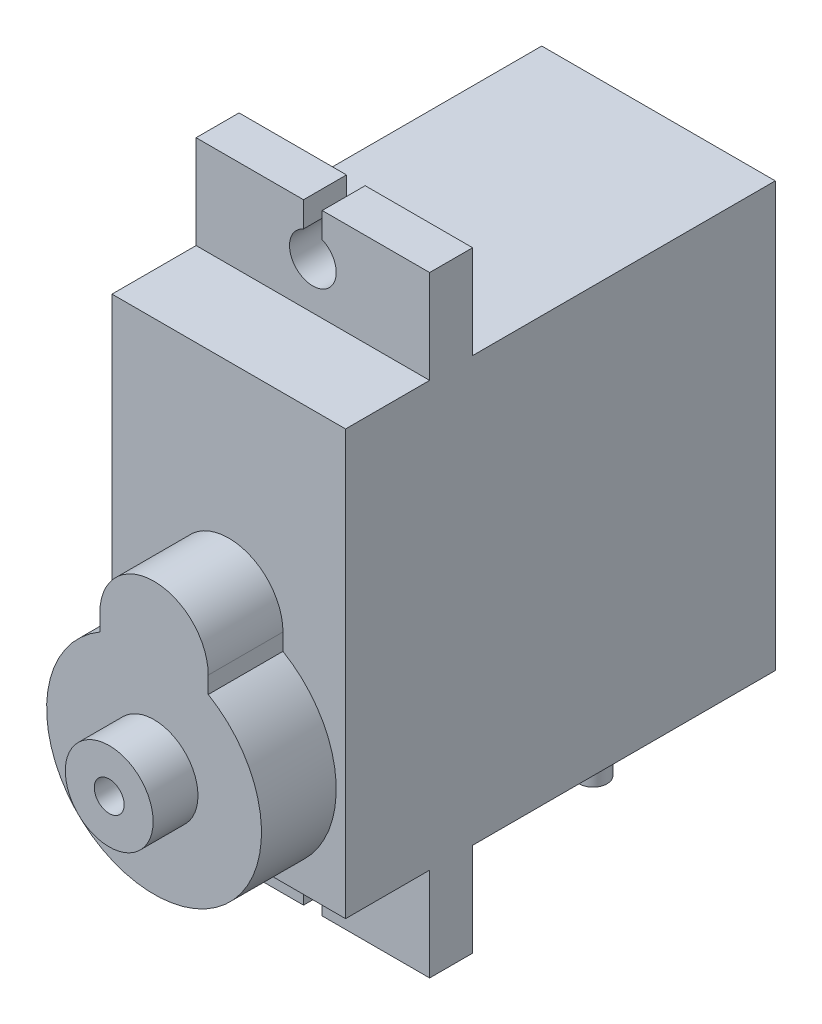
from build123d import *

# Parameters (mm, degrees)
SKETCH1_W           = 12.5
SKETCH1_H           = 22.7
BOSS_EXTRUDE1_DEPTH = 23
BOSS_EXTRUDE2_DEPTH = 4
SKETCH3_W           = 2.3
SKETCH3_H           = 5
BOSS_EXTRUDE3_DEPTH = 6.25
CUT_EXTRUDE1_REACH  = 20.5
BOSS_EXTRUDE4_START = -4
SKETCH5_W           = 4
SKETCH5_H           = 5
BOSS_EXTRUDE4_DEPTH = 1.5
SKETCH6_R           = 2.35
SKETCH6_R_2         = 0.8
BOSS_EXTRUDE5_DEPTH = 2.4
SKETCH7_W           = 4.514706964
SKETCH7_H           = 2.103718672
CUT_EXTRUDE2_DEPTH  = 5


with BuildPart() as part:
    # Sketch1 → Boss-Extrude1 (new body)
    with BuildSketch(Plane.XY):
        Rectangle(SKETCH1_W, SKETCH1_H)
    extrude(amount=BOSS_EXTRUDE1_DEPTH)

    # Sketch2 → Boss-Extrude2 (add)
    with BuildSketch(Plane.XY.offset(23)):
        with BuildLine():
            Line((2.9, 0.265128397), (2.9, -0.634871603))
            ThreePointArc((2.9, -0.634871603), (0, -11.35), (-2.9, -0.634871603))
            Line((-2.9, -0.634871603), (-2.9, 0.265128397))
            ThreePointArc((-2.9, 0.265128397), (0, 3.165128397), (2.9, 0.265128397))
        make_face()
    extrude(amount=BOSS_EXTRUDE2_DEPTH)

    # Sketch3 → Boss-Extrude3 (add, symmetric)
    with BuildSketch(Plane(origin=(0, 0, 0), x_dir=(0, 0, -1), z_dir=(1, 0, 0))):
        with Locations((-17.35, 13.85)):
            Rectangle(SKETCH3_W, SKETCH3_H)
        with Locations((-17.35, -13.85)):
            Rectangle(SKETCH3_W, SKETCH3_H)
    extrude(amount=BOSS_EXTRUDE3_DEPTH, both=True)

    # Sketch4 → Cut-Extrude1 (cut, up to next)
    with BuildSketch(Plane.XY.offset(18.5), mode=Mode.PRIVATE) as cut_extrude1_sk1:
        with BuildLine():
            Line((0.5, 16.35), (-0.5, 16.35))
            Line((-0.5, 16.35), (-0.5, 14.995643924))
            ThreePointArc((-0.5, 14.995643924), (0, 12.6), (0.5, 14.995643924))
            Line((0.5, 14.995643924), (0.5, 16.35))
        make_face()
    cut_extrude1_tool1 = extrude(cut_extrude1_sk1.sketch, amount=-CUT_EXTRUDE1_REACH, mode=Mode.PRIVATE) & part.part
    add(cut_extrude1_tool1.solids().sort_by_distance((0, 14.235184, 18.5))[0], mode=Mode.SUBTRACT)
    # Sketch4 → Cut-Extrude1 (cut, up to next)
    with BuildSketch(Plane.XY.offset(18.5), mode=Mode.PRIVATE) as cut_extrude1_sk2:
        with BuildLine():
            Line((-0.5, -16.35), (-0.5, -14.995643924))
            ThreePointArc((-0.5, -14.995643924), (0, -12.6), (0.5, -14.995643924))
            Line((0.5, -14.995643924), (0.5, -16.35))
            Line((0.5, -16.35), (-0.5, -16.35))
        make_face()
    cut_extrude1_tool2 = extrude(cut_extrude1_sk2.sketch, amount=-CUT_EXTRUDE1_REACH, mode=Mode.PRIVATE) & part.part
    add(cut_extrude1_tool2.solids().sort_by_distance((0, -14.235184, 18.5))[0], mode=Mode.SUBTRACT)

    # Sketch5 → Boss-Extrude4 (add)
    with BuildSketch(Plane(origin=(0, 0, 0), x_dir=(-1, 0, 0), z_dir=(0, 0, -1)).offset(BOSS_EXTRUDE4_START)):
        with Locations((0, -13.85)):
            Rectangle(SKETCH5_W, SKETCH5_H)
    extrude(amount=-BOSS_EXTRUDE4_DEPTH)

    # Sketch6 → Boss-Extrude5 (add)
    with BuildSketch(Plane.XY.offset(27)):
        with Locations((0, -5.6)):
            Circle(SKETCH6_R)
        with Locations((0, -5.6)):
            Circle(SKETCH6_R_2, mode=Mode.SUBTRACT)
    extrude(amount=BOSS_EXTRUDE5_DEPTH)

    # Sketch7 → Cut-Extrude2 (cut)
    with BuildSketch(Plane.XZ.offset(16.35)):
        with Locations((0, 4.75)):
            Rectangle(SKETCH7_W, SKETCH7_H)
        with BuildLine():
            ThreePointArc((-0.625, 4.335421901), (-2, 4.75), (-0.625, 5.164578099))
            ThreePointArc((-0.625, 5.164578099), (0, 5.5), (0.625, 5.164578099))
            ThreePointArc((0.625, 5.164578099), (2, 4.75), (0.625, 4.335421901))
            ThreePointArc((0.625, 4.335421901), (0, 4), (-0.625, 4.335421901))
        make_face(mode=Mode.SUBTRACT)
    extrude(amount=-CUT_EXTRUDE2_DEPTH, mode=Mode.SUBTRACT)


solid = part.part
